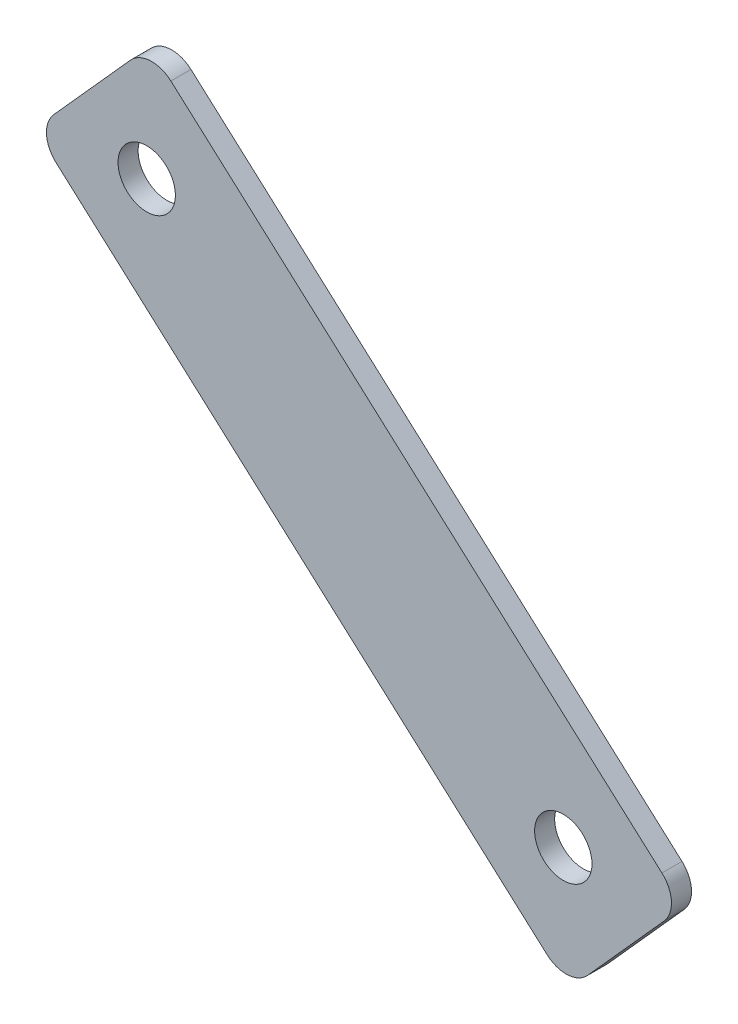
from build123d import *

# Parameters (mm, degrees)
BOSS_EXTRUDE1_DEPTH = 7
FILLET1_R           = 10
SKETCH3_R           = 10
CUT_EXTRUDE1_DEPTH  = 7
SCALE1_SCALE        = 0.2
SCALE2_SCALE        = 2.5
SCALE3_SCALE        = 0.8


with BuildPart() as part:
    # Sketch1 → Boss-Extrude1 (new body)
    with BuildSketch(Plane.XY):
        Polygon((0, 0), (40.058778279, 44.668717049), (-146.060876092, 211.580293211), (-186.119654371, 166.911576162), align=None)
    extrude(amount=BOSS_EXTRUDE1_DEPTH)

    # Fillet1
    fillet1_edges = [part.edges().sort_by_distance(p)[0] for p in [
        (-186.119654371, 166.911576162, 3.5),
        (-146.060876092, 211.580293211, 3.5),
        (40.058778279, 44.668717049, 3.5),
        (0, 0, 3.5),
    ]]
    fillet(fillet1_edges, radius=FILLET1_R)

    # Sketch3 → Cut-Extrude1 (cut)
    with BuildSketch(Plane.XY.offset(7)):
        with Locations((-1.778551095, 41.89165724)):
            Circle(SKETCH3_R)
        with Locations((-147.041782503, 171.152655791)):
            Circle(SKETCH3_R)
    extrude(amount=-CUT_EXTRUDE1_DEPTH, mode=Mode.SUBTRACT)


with BuildPart() as part_1:
    # Scale1: scaled about (-72.969754943, 105.757951413, 3.5)
    add(part.part.scale(SCALE1_SCALE).moved(Location((-58.375803954, 84.60636113, 2.8))))


with BuildPart() as part_2:
    # Scale2: scaled about (-72.969754943, 105.757951413, 3.5)
    add(part_1.part.scale(SCALE2_SCALE).moved(Location((109.454632414, -158.63692712, -5.25))))


with BuildPart() as part_3:
    # Scale3: scaled about (-72.969754943, 105.757951413, 3.5)
    add(part_2.part.scale(SCALE3_SCALE).moved(Location((-14.593950989, 21.151590283, 0.7))))


solid = part_3.part
